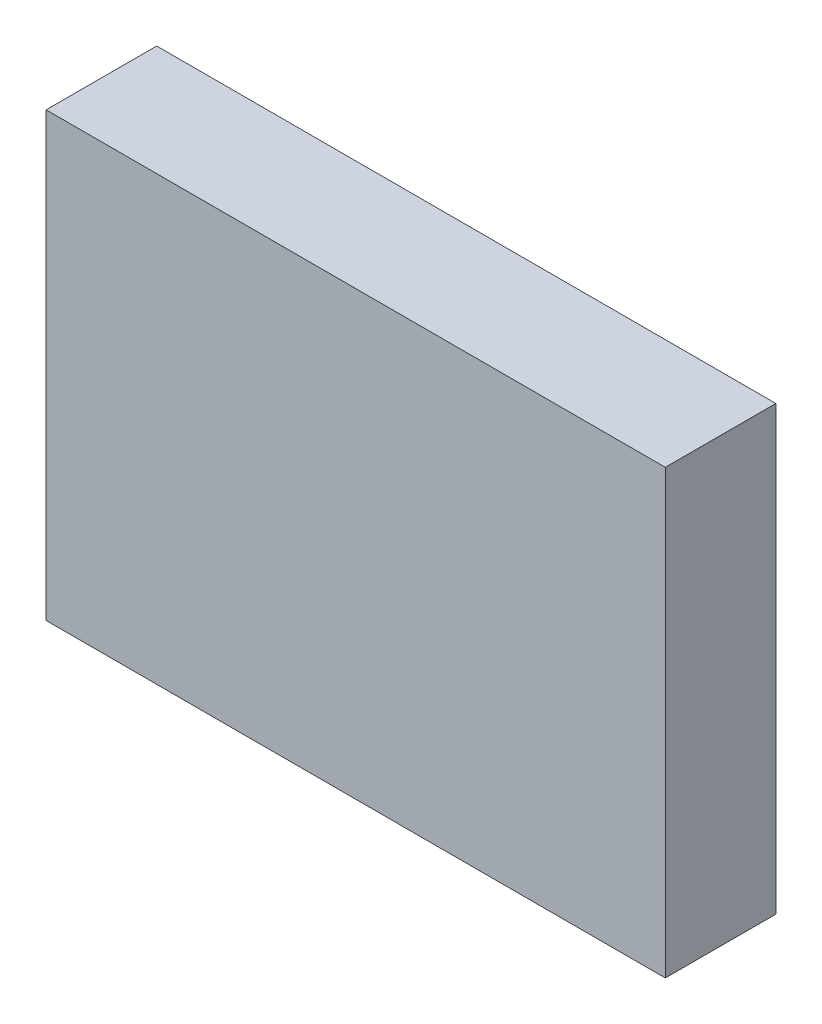
from build123d import *

# Parameters (mm, degrees)
SKETCH1_W           = 28
SKETCH1_H           = 20
BOSS_EXTRUDE1_DEPTH = 5


with BuildPart() as part:
    # Sketch1 → Boss-Extrude1 (new body)
    with BuildSketch(Plane.XY):
        Rectangle(SKETCH1_W, SKETCH1_H)
    extrude(amount=BOSS_EXTRUDE1_DEPTH)


solid = part.part
